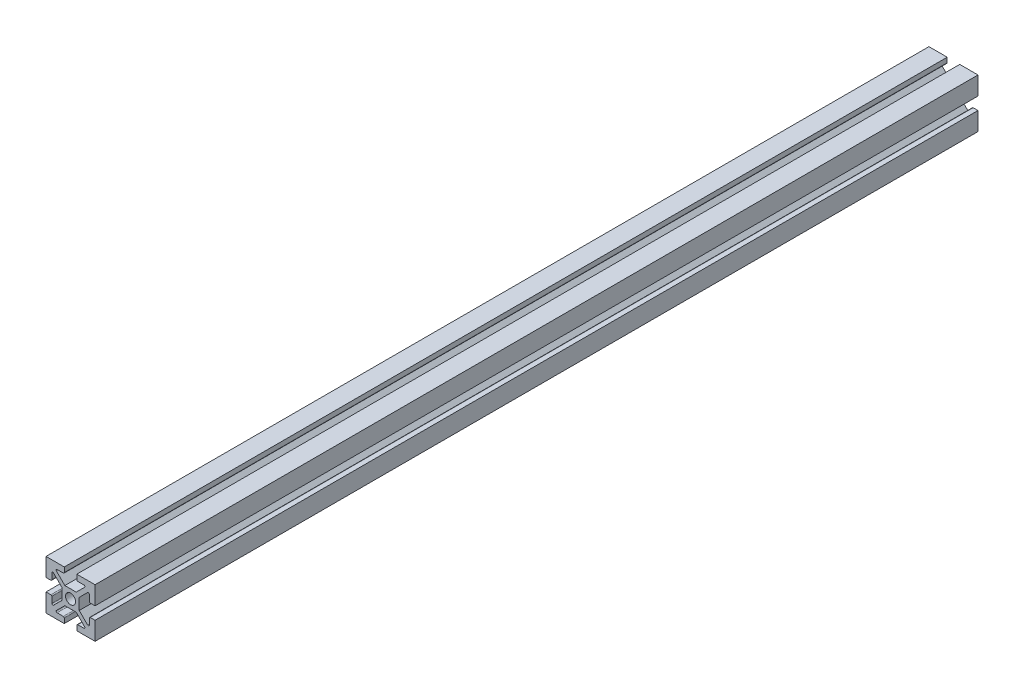
from build123d import *

# Parameters (mm, degrees)
SKETCH2_W           = 25.4
SKETCH2_H           = 25.4
BOSS_EXTRUDE2_DEPTH = 457.2
SKETCH3_R           = 2.6035
CUT_EXTRUDE2_DEPTH  = 458.2


with BuildPart() as part:
    # Sketch2 → Boss-Extrude2 (new body)
    with BuildSketch(Plane.XY):
        Rectangle(SKETCH2_W, SKETCH2_H)
    extrude(amount=BOSS_EXTRUDE2_DEPTH)

    # Sketch3 → Cut-Extrude2 (cut, through all)
    with BuildSketch(Plane.XY.offset(457.2)):
        Circle(SKETCH3_R)
        with BuildLine():
            Line((-3.2385, 12.7), (-3.2385, 10.218485055))
            ThreePointArc((-3.2385, 10.218485055), (-3.387289755, 9.85927481), (-3.7465, 9.710485055))
            Line((-3.7465, 9.710485055), (-6.9215, 9.710485055))
            ThreePointArc((-6.9215, 9.710485055), (-7.390830803, 9.396888238), (-7.280710245, 8.84327481))
            Line((-7.280710245, 8.84327481), (-2.945935435, 4.5085))
            Line((-2.945935435, 4.5085), (2.945935435, 4.5085))
            Line((2.945935435, 4.5085), (7.280710245, 8.84327481))
            ThreePointArc((7.280710245, 8.84327481), (7.390830803, 9.396888238), (6.9215, 9.710485055))
            Line((6.9215, 9.710485055), (3.7465, 9.710485055))
            ThreePointArc((3.7465, 9.710485055), (3.387289755, 9.85927481), (3.2385, 10.218485055))
            Line((3.2385, 10.218485055), (3.2385, 12.7))
            Line((3.2385, 12.7), (-3.2385, 12.7))
        make_face()
        with BuildLine():
            Line((12.7, 3.2385), (10.218485055, 3.2385))
            ThreePointArc((10.218485055, 3.2385), (9.85927481, 3.387289755), (9.710485055, 3.7465))
            Line((9.710485055, 3.7465), (9.710485055, 6.9215))
            ThreePointArc((9.710485055, 6.9215), (9.396888238, 7.390830803), (8.84327481, 7.280710245))
            Line((8.84327481, 7.280710245), (4.5085, 2.945935435))
            Line((4.5085, 2.945935435), (4.5085, -2.945935435))
            Line((4.5085, -2.945935435), (8.84327481, -7.280710245))
            ThreePointArc((8.84327481, -7.280710245), (9.396888238, -7.390830803), (9.710485055, -6.9215))
            Line((9.710485055, -6.9215), (9.710485055, -3.7465))
            ThreePointArc((9.710485055, -3.7465), (9.85927481, -3.387289755), (10.218485055, -3.2385))
            Line((10.218485055, -3.2385), (12.7, -3.2385))
            Line((12.7, -3.2385), (12.7, 3.2385))
        make_face()
        with BuildLine():
            Line((3.2385, -12.7), (3.2385, -10.218485055))
            ThreePointArc((3.2385, -10.218485055), (3.387289755, -9.85927481), (3.7465, -9.710485055))
            Line((3.7465, -9.710485055), (6.9215, -9.710485055))
            ThreePointArc((6.9215, -9.710485055), (7.390830803, -9.396888238), (7.280710245, -8.84327481))
            Line((7.280710245, -8.84327481), (2.945935435, -4.5085))
            Line((2.945935435, -4.5085), (-2.945935435, -4.5085))
            Line((-2.945935435, -4.5085), (-7.280710245, -8.84327481))
            ThreePointArc((-7.280710245, -8.84327481), (-7.390830803, -9.396888238), (-6.9215, -9.710485055))
            Line((-6.9215, -9.710485055), (-3.7465, -9.710485055))
            ThreePointArc((-3.7465, -9.710485055), (-3.387289755, -9.85927481), (-3.2385, -10.218485055))
            Line((-3.2385, -10.218485055), (-3.2385, -12.7))
            Line((-3.2385, -12.7), (3.2385, -12.7))
        make_face()
        with BuildLine():
            Line((-12.7, -3.2385), (-10.218485055, -3.2385))
            ThreePointArc((-10.218485055, -3.2385), (-9.85927481, -3.387289755), (-9.710485055, -3.7465))
            Line((-9.710485055, -3.7465), (-9.710485055, -6.9215))
            ThreePointArc((-9.710485055, -6.9215), (-9.396888238, -7.390830803), (-8.84327481, -7.280710245))
            Line((-8.84327481, -7.280710245), (-4.5085, -2.945935435))
            Line((-4.5085, -2.945935435), (-4.5085, 2.945935435))
            Line((-4.5085, 2.945935435), (-8.84327481, 7.280710245))
            ThreePointArc((-8.84327481, 7.280710245), (-9.396888238, 7.390830803), (-9.710485055, 6.9215))
            Line((-9.710485055, 6.9215), (-9.710485055, 3.7465))
            ThreePointArc((-9.710485055, 3.7465), (-9.85927481, 3.387289755), (-10.218485055, 3.2385))
            Line((-10.218485055, 3.2385), (-12.7, 3.2385))
            Line((-12.7, 3.2385), (-12.7, -3.2385))
        make_face()
    extrude(amount=-CUT_EXTRUDE2_DEPTH, mode=Mode.SUBTRACT)


solid = part.part
